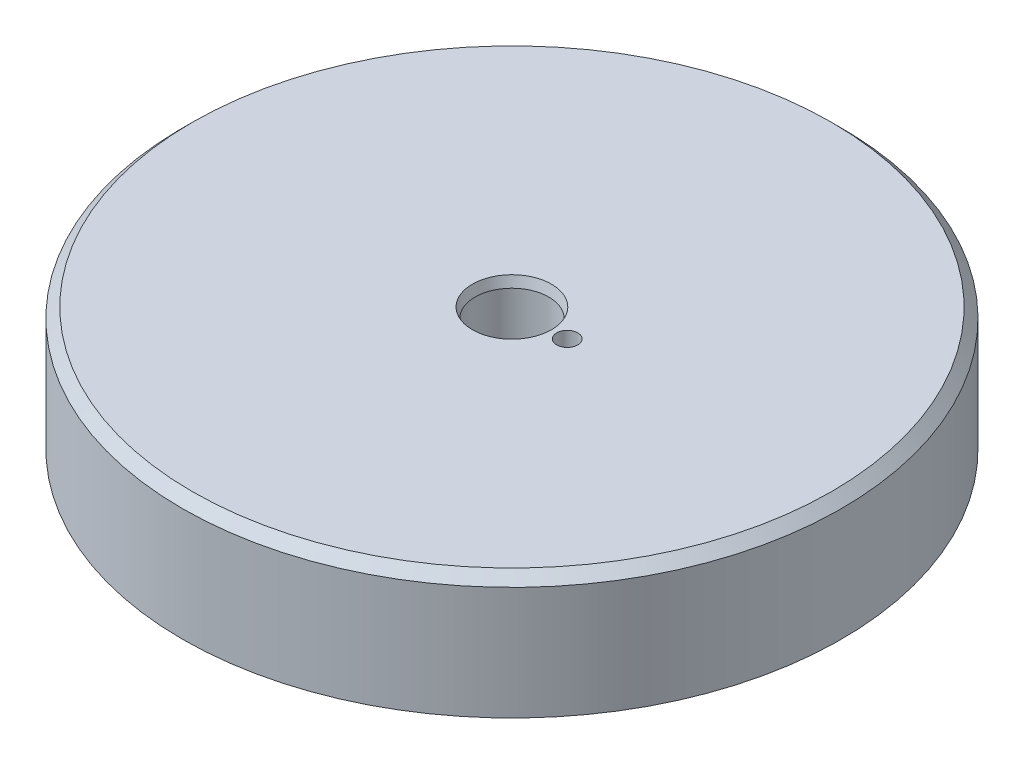
from build123d import *

# Parameters (mm, degrees)
SKETCH1_R                   = 42.545
BOSS_EXTRUDE1_DEPTH         = 15.875
SKETCH2_R                   = 39.3446
SKETCH2_R_2                 = 34.7218
GROOVE_232ORING_DEPTH       = 2.6416
F_1_4_20_TAPPED_HOLE1_D     = 5.1054
F_1_4_20_TAPPED_HOLE1_DEPTH = 7.874
F_1_4_20_TAPPED_HOLE1_TIP   = 1.533816902
SKETCH7_R                   = 4.7625
CUT_EXTRUDE2_DEPTH          = 16.875
SKETCH8_R                   = 1.3589
CUT_EXTRUDE3_DEPTH          = 3.302
CHAMFER1_SIZE               = 0.340295474
CHAMFER1_SIZE2              = 1.27
CHAMFER2_SIZE               = 1.27
FILLET1_R                   = 0.254


with BuildPart() as part:
    # Sketch1 → Boss-Extrude1 (new body)
    with BuildSketch(Plane.XZ):
        Circle(SKETCH1_R)
    extrude(amount=-BOSS_EXTRUDE1_DEPTH)

    # Sketch2 → Groove_232Oring (cut)
    with BuildSketch(Plane.XZ):
        Circle(SKETCH2_R)
        Circle(SKETCH2_R_2, mode=Mode.SUBTRACT)
    extrude(amount=-GROOVE_232ORING_DEPTH, mode=Mode.SUBTRACT)

    # 1/4-20 Tapped Hole1
    with Locations(Plane(origin=(0, 0, 0), x_dir=(-1, 0, 0), z_dir=(0, -1, 0))):
        with Locations((-7.395754214, 27.601330486), (7.395754214, -27.601330486)):
            Hole(F_1_4_20_TAPPED_HOLE1_D / 2, depth=F_1_4_20_TAPPED_HOLE1_DEPTH)
            with Locations((0, 0, -(F_1_4_20_TAPPED_HOLE1_DEPTH + F_1_4_20_TAPPED_HOLE1_TIP / 2))):  # 118° drill point
                Cone(0, F_1_4_20_TAPPED_HOLE1_D / 2, F_1_4_20_TAPPED_HOLE1_TIP, mode=Mode.SUBTRACT)

    # Sketch7 → Cut-Extrude2 (cut, through all)
    with BuildSketch(Plane(origin=(0, 15.875, 0), x_dir=(-1, 0, 0), z_dir=(0, 1, 0))):
        Circle(SKETCH7_R)
    extrude(amount=-CUT_EXTRUDE2_DEPTH, mode=Mode.SUBTRACT)

    # Sketch8 → Cut-Extrude3 (cut)
    with BuildSketch(Plane(origin=(0, 15.875, 0), x_dir=(-1, 0, 0), z_dir=(0, 1, 0))):
        with Locations((-7.1374, 0)):
            Circle(SKETCH8_R)
    extrude(amount=-CUT_EXTRUDE3_DEPTH, mode=Mode.SUBTRACT)

    # Chamfer1
    chamfer1_edges = [part.edges().sort_by_distance(p)[0] for p in [
        (4.7625, 15.875, 0),
    ]]
    chamfer1_side = [part.faces().sort_by_distance(p)[0] for p in [
        (-41.34164568, 15.875, 0),
    ]]
    chamfer(chamfer1_edges, length=CHAMFER1_SIZE, length2=CHAMFER1_SIZE2, reference=chamfer1_side[0])

    # Chamfer2
    chamfer2_edges = [part.edges().sort_by_distance(p)[0] for p in [
        (-42.545, 15.875, 0),
    ]]
    chamfer(chamfer2_edges, length=CHAMFER2_SIZE)

    # Fillet1
    fillet1_edges = [part.edges().sort_by_distance(p)[0] for p in [
        (-39.3446, 2.6416, 0),
        (-34.7218, 2.6416, 0),
        (-39.3446, 0, 0),
        (-34.7218, 0, 0),
    ]]
    fillet(fillet1_edges, radius=FILLET1_R)


solid = part.part
